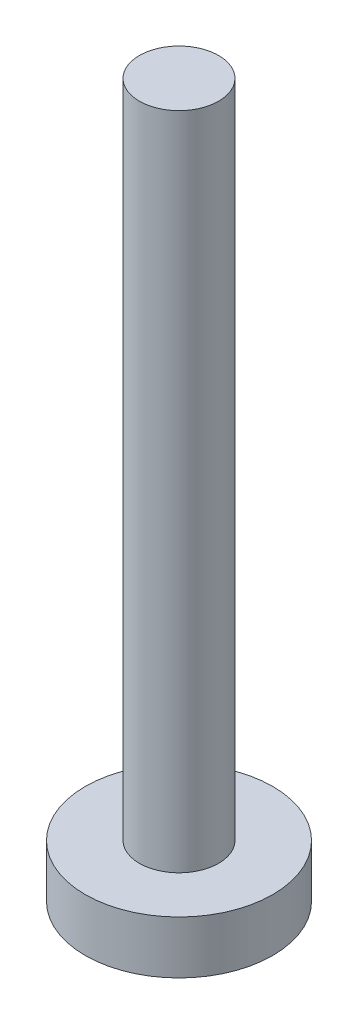
from build123d import *

# Parameters (mm, degrees)
SKETCH_1_R      = 3.55
EXTRUDE_1_DEPTH = 2
SKETCH_2_R      = 1.5
EXTRUDE_2_DEPTH = 25


with BuildPart() as part:
    # 草图1 → 凸台-拉伸1 (new body)
    with BuildSketch(Plane(origin=(0, 0, 0), x_dir=(1, 0, 0), z_dir=(0, 1, 0))):
        Circle(SKETCH_1_R)
    extrude(amount=EXTRUDE_1_DEPTH)

    # 草图2 → 凸台-拉伸2 (add)
    with BuildSketch(Plane(origin=(0, 2, 0), x_dir=(1, 0, 0), z_dir=(0, 1, 0))):
        Circle(SKETCH_2_R)
    extrude(amount=EXTRUDE_2_DEPTH)


solid = part.part
